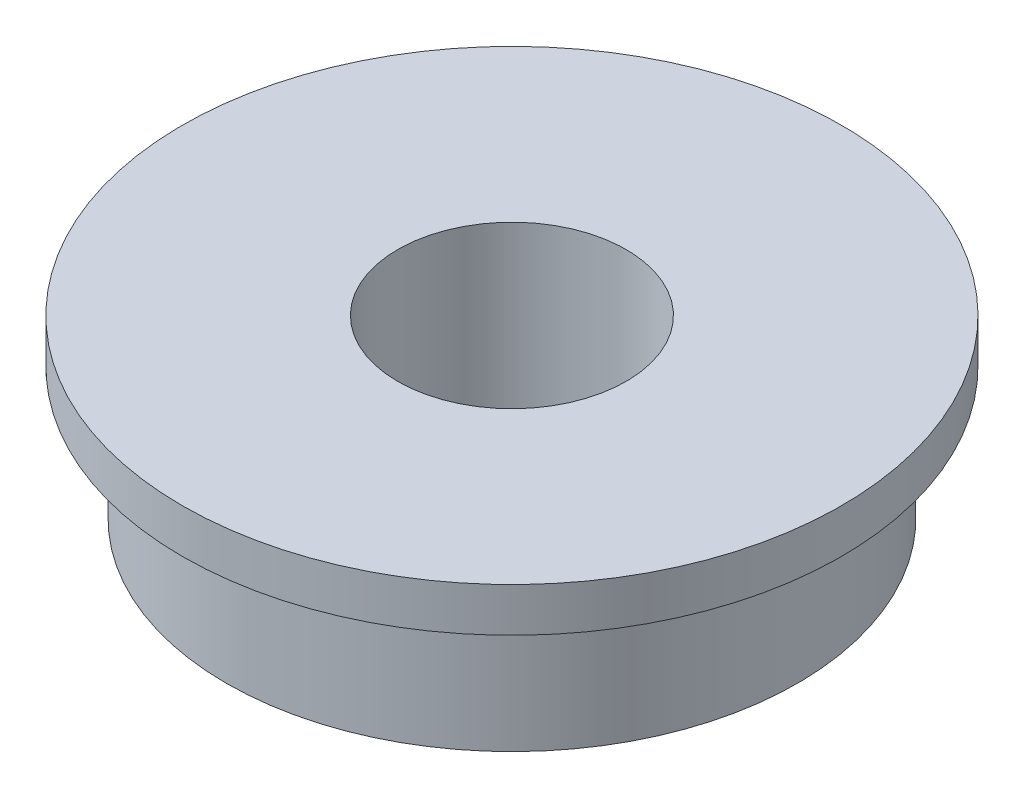
from build123d import *

# Parameters (mm, degrees)
SKETCH_1_R      = 6.5
SKETCH_1_R_2    = 2.6
EXTRUDE_1_DEPTH = 4
SKETCH_2_R      = 7.5
SKETCH_2_R_2    = 2.6
EXTRUDE_2_DEPTH = 1


with BuildPart() as part:
    # 草图1 → 凸台-拉伸1 (new body)
    with BuildSketch(Plane(origin=(0, 0, 0), x_dir=(1, 0, 0), z_dir=(0, 1, 0))):
        Circle(SKETCH_1_R)
        Circle(SKETCH_1_R_2, mode=Mode.SUBTRACT)
    extrude(amount=EXTRUDE_1_DEPTH)

    # 草图2 → 凸台-拉伸2 (add)
    with BuildSketch(Plane(origin=(0, 4, 0), x_dir=(1, 0, 0), z_dir=(0, 1, 0))):
        Circle(SKETCH_2_R)
        Circle(SKETCH_2_R_2, mode=Mode.SUBTRACT)
    extrude(amount=-EXTRUDE_2_DEPTH)


solid = part.part
